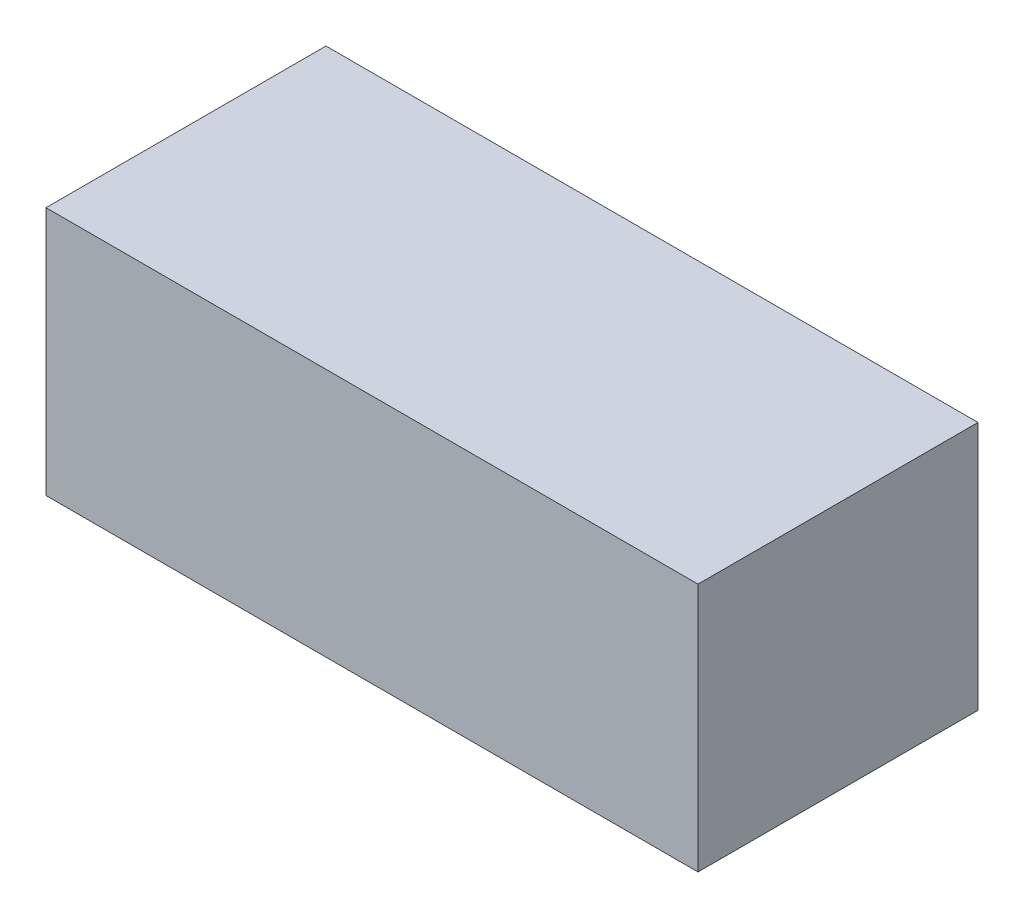
from build123d import *

# Parameters (mm, degrees)
SKETCH1_W           = 43.18
SKETCH1_H           = 18.542
BOSS_EXTRUDE1_DEPTH = 16.51


with BuildPart() as part:
    # Sketch1 → Boss-Extrude1 (new body)
    with BuildSketch(Plane(origin=(0, 0, 0), x_dir=(1, 0, 0), z_dir=(0, 1, 0))):
        Rectangle(SKETCH1_W, SKETCH1_H)
    extrude(amount=BOSS_EXTRUDE1_DEPTH)


solid = part.part
